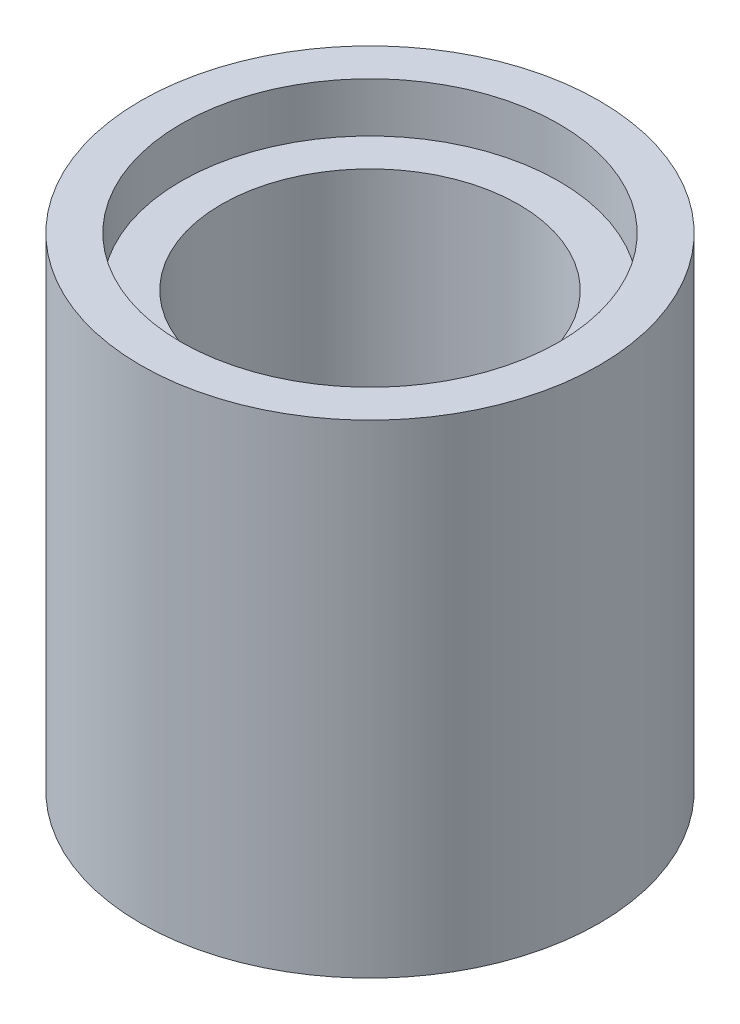
from build123d import *

# Parameters (mm, degrees)
SKETCH1_R           = 3.7
BOSS_EXTRUDE3_DEPTH = 7.8
SKETCH2_R           = 2.4
CUT_EXTRUDE6_DEPTH  = 7.8
SKETCH3_R           = 3.05
CUT_EXTRUDE7_DEPTH  = 0.8
SKETCH4_R           = 3.05
CUT_EXTRUDE8_DEPTH  = 0.8


with BuildPart() as part:
    # Sketch1 → Boss-Extrude3 (new body)
    with BuildSketch(Plane(origin=(0, 0, 0), x_dir=(1, 0, 0), z_dir=(0, 1, 0))):
        with Locations((-16, 0)):
            Circle(SKETCH1_R)
    extrude(amount=BOSS_EXTRUDE3_DEPTH)

    # Sketch2 → Cut-Extrude6 (cut)
    with BuildSketch(Plane(origin=(0, 7.8, 0), x_dir=(1, 0, 0), z_dir=(0, 1, 0))):
        with Locations((-16, 0)):
            Circle(SKETCH2_R)
    extrude(amount=-CUT_EXTRUDE6_DEPTH, mode=Mode.SUBTRACT)

    # Sketch3 → Cut-Extrude7 (cut)
    with BuildSketch(Plane(origin=(0, 7.8, 0), x_dir=(1, 0, 0), z_dir=(0, 1, 0))):
        with Locations((-16, 0)):
            Circle(SKETCH3_R)
    extrude(amount=-CUT_EXTRUDE7_DEPTH, mode=Mode.SUBTRACT)

    # Sketch4 → Cut-Extrude8 (cut)
    with BuildSketch(Plane.XZ):
        with Locations((-16, 0)):
            Circle(SKETCH4_R)
    extrude(amount=-CUT_EXTRUDE8_DEPTH, mode=Mode.SUBTRACT)


solid = part.part
